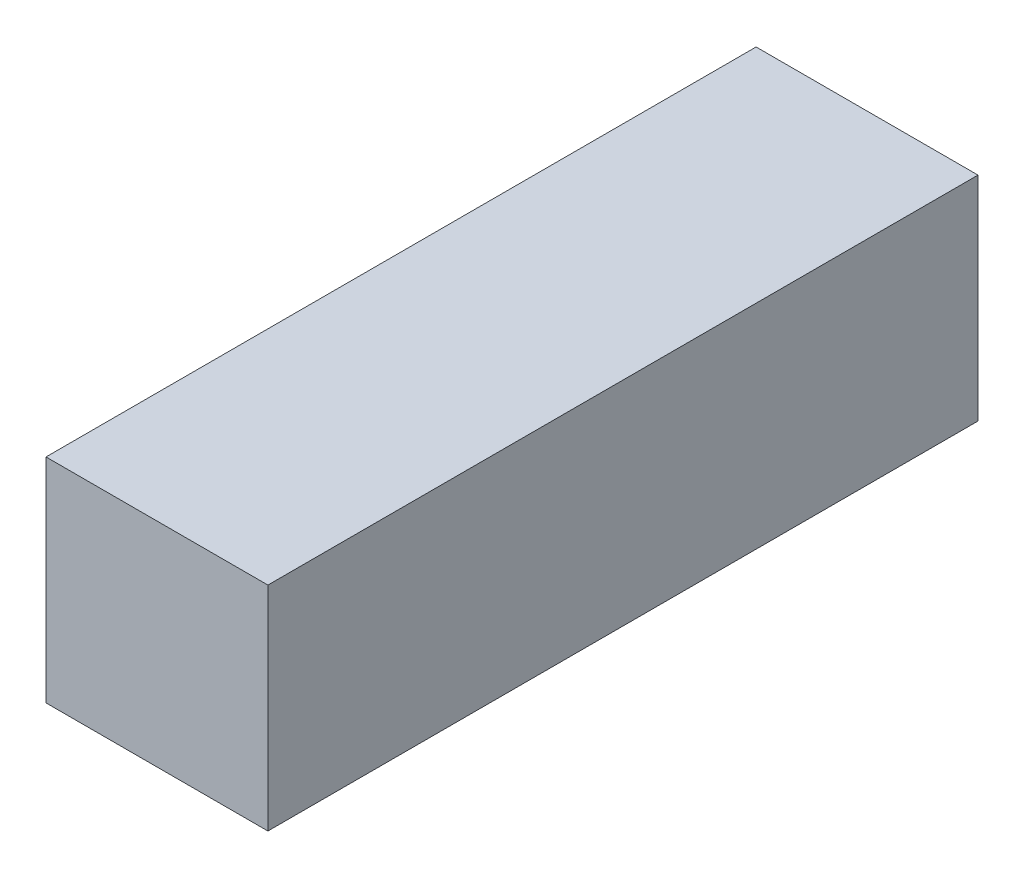
from build123d import *

# Parameters (mm, degrees)
SCHIZZO1_W                   = 50
SCHIZZO1_H                   = 160
ESTRUSIONE_ESTRUSIONE1_DEPTH = 48


with BuildPart() as part:
    # Schizzo1 → Estrusione-Estrusione1 (new body)
    with BuildSketch(Plane(origin=(0, 2575.798986946, 0), x_dir=(-1, 0, 0), z_dir=(0, -1, 0))):
        with Locations((379.161717832, -2737.206867031)):
            Rectangle(SCHIZZO1_W, SCHIZZO1_H)
    extrude(amount=ESTRUSIONE_ESTRUSIONE1_DEPTH)


solid = part.part
